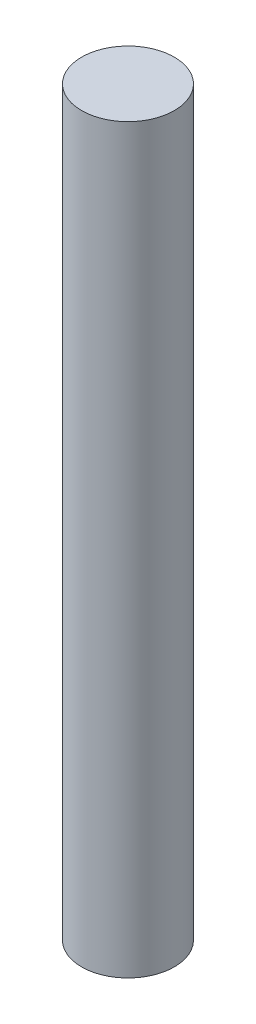
from build123d import *

# Parameters (mm, degrees)
SKETCH_1_R      = 1.5
EXTRUDE_1_DEPTH = 24


with BuildPart() as part:
    # 草图1 → 凸台-拉伸1 (new body)
    with BuildSketch(Plane(origin=(0, 0, 0), x_dir=(1, 0, 0), z_dir=(0, 1, 0))):
        Circle(SKETCH_1_R)
    extrude(amount=EXTRUDE_1_DEPTH)


solid = part.part
